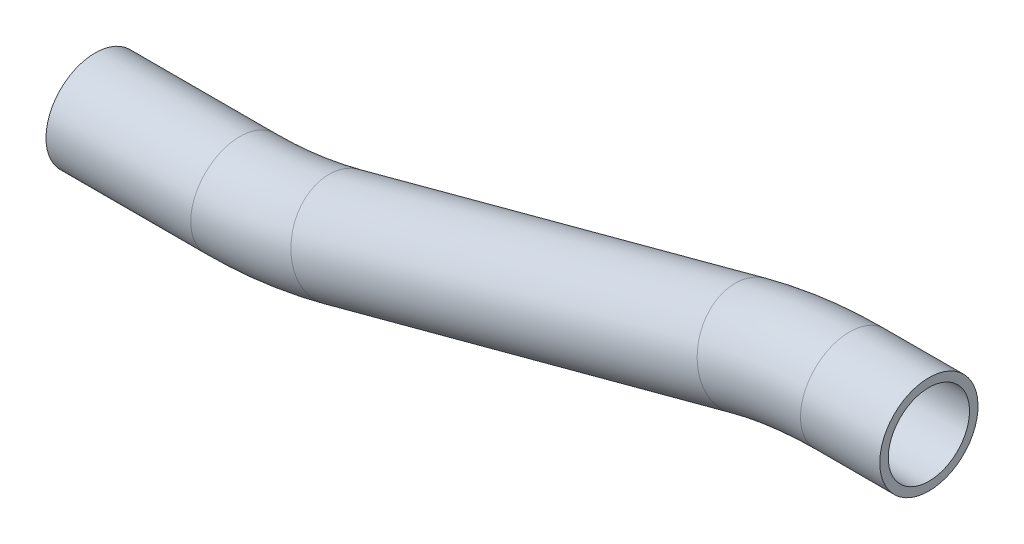
from build123d import *

# Parameters (mm, degrees)
SKETCH2_R   = 9.525
SKETCH2_R_2 = 7.874


with BuildPart() as part:
    # Sweep1: sweep along a path in Sketch1
    with BuildLine(Plane.XY) as sweep1_path:
        Line((15.368079684, 0), (0, 0))
        ThreePointArc((0, 0), (-9.946095847, -0.651901563), (-19.722011237, -2.596452037))
        Line((-19.722011237, -2.596452037), (-98.479893346, -23.699562946))
        ThreePointArc((-98.479893346, -23.699562946), (-108.255808736, -25.644113419), (-118.201904583, -26.296014982))
        Line((-118.201904583, -26.296014982), (-146.269984267, -26.296014982))
    # Sketch2 → Sweep1 (sweep)
    with BuildSketch(Plane.ZY.offset(-15.368079684)):
        Circle(SKETCH2_R)
        Circle(SKETCH2_R_2, mode=Mode.SUBTRACT)
    sweep(path=sweep1_path.line)


solid = part.part
